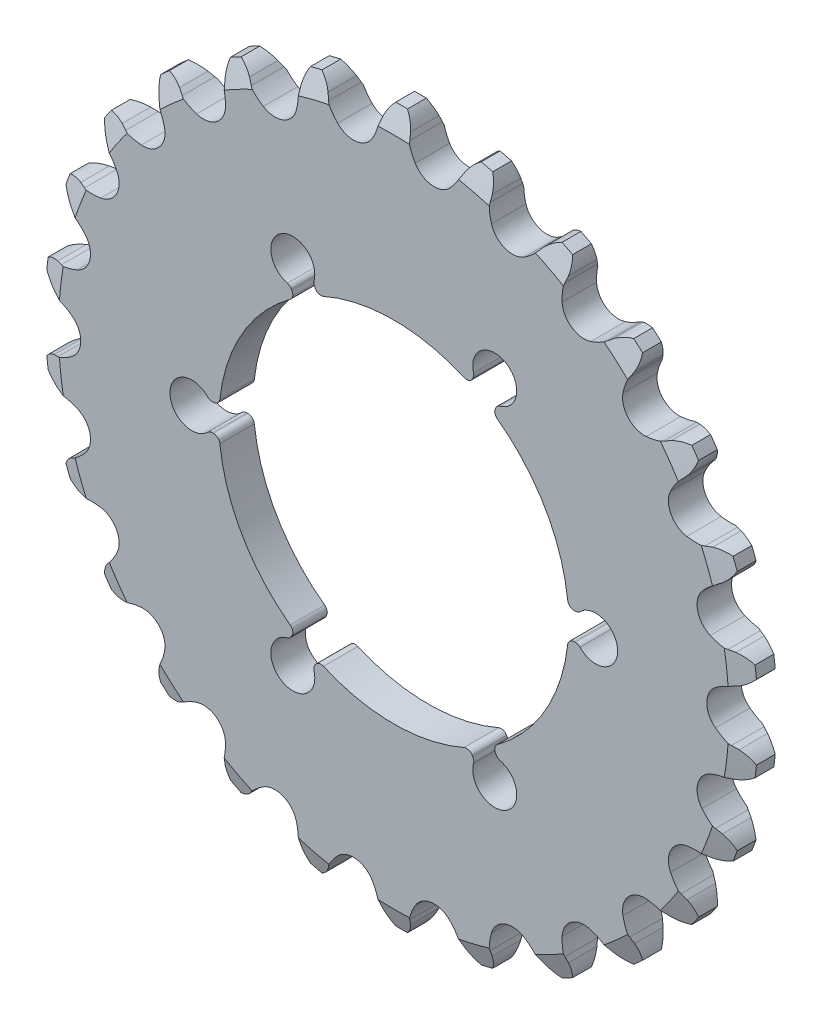
from build123d import *

# Parameters (mm, degrees)
SKETCH1_R         = 42.08018
SKETCH1_R_2       = 20.6375
EXTRUDE1_DEPTH    = 2.032
EXTRUDE2_DEPTH    = 3.032
CIRPATTERN1_COUNT = 6
CHAMFER1_SIZE     = 2.54
CHAMFER1_SIZE2    = 0.924484395
CHAMFER2_SIZE     = 2.54
CHAMFER2_SIZE2    = 0.924484395
EXTRUDE3_DEPTH    = 3.032
CIRPATTERN2_COUNT = 26
FILLET1_R         = 0.762


with BuildPart() as part:
    # Sketch1 → Extrude1 (new body, symmetric)
    with BuildSketch(Plane.XY):
        Circle(SKETCH1_R)
        Circle(SKETCH1_R_2, mode=Mode.SUBTRACT)
    extrude(amount=EXTRUDE1_DEPTH, both=True)

    # Sketch2 → Extrude2 (cut, symmetric)
    with BuildSketch(Plane.XY):
        with BuildLine():
            Line((8.91336053, 18.613393305), (9.507705167, 19.642828413))
            ThreePointArc((9.507705167, 19.642828413), (13.20165, 22.865928544), (12.257335824, 18.055328413))
            Line((12.257335824, 18.055328413), (11.662991187, 17.025893305))
            ThreePointArc((11.662991187, 17.025893305), (10.31875, 17.872599271), (8.91336053, 18.613393305))
        make_face()
    extrude2 = extrude(amount=EXTRUDE2_DEPTH, both=True, mode=Mode.SUBTRACT)

    # CirPattern1: Extrude2 ×6 about axis
    cirpattern1_axis = Axis((0, 0, 0), (0, 0, 1))
    for i in range(1, CIRPATTERN1_COUNT):
        add(extrude2.rotate(cirpattern1_axis, i * 360 / CIRPATTERN1_COUNT), mode=Mode.SUBTRACT)

    # Chamfer1
    chamfer1_edges = [part.edges().sort_by_distance(p)[0] for p in [
        (-42.08018, 0, 2.032),
    ]]
    chamfer1_side = [part.faces().sort_by_distance(p)[0] for p in [
        (-40.889972775, 0, 2.032),
    ]]
    chamfer(chamfer1_edges, length=CHAMFER1_SIZE, length2=CHAMFER1_SIZE2, reference=chamfer1_side[0])

    # Chamfer2
    chamfer2_edges = [part.edges().sort_by_distance(p)[0] for p in [
        (-42.08018, 0, -2.032),
    ]]
    chamfer2_side = [part.faces().sort_by_distance(p)[0] for p in [
        (-40.889972775, 0, -2.032),
    ]]
    chamfer(chamfer2_edges, length=CHAMFER2_SIZE, length2=CHAMFER2_SIZE2, reference=chamfer2_side[0])

    # Sketch3 → Extrude3 (cut, symmetric)
    with BuildSketch(Plane.XY):
        with BuildLine():
            Line((1.783603898, 39.799359762), (1.630155707, 40.477947689))
            ThreePointArc((1.630155707, 40.477947689), (1.253812639, 41.328387), (0.6985, 42.074382308))
            ThreePointArc((0.6985, 42.074382308), (5.072205202, 41.77336811), (9.390855892, 41.018939217))
            ThreePointArc((9.390855892, 41.018939217), (8.673151267, 40.427516189), (8.104220595, 39.691853891))
            Line((8.104220595, 39.691853891), (7.792834609, 39.069707052))
            ThreePointArc((7.792834609, 39.069707052), (7.271379963, 38.200463336), (6.623864243, 37.420576821))
            ThreePointArc((6.623864243, 37.420576821), (4.450208219, 36.650762084), (2.523943414, 37.918397339))
            ThreePointArc((2.523943414, 37.918397339), (2.081882383, 38.830582424), (1.783603898, 39.799359762))
        make_face()
    extrude3 = extrude(amount=EXTRUDE3_DEPTH, both=True, mode=Mode.SUBTRACT)

    # CirPattern2: Extrude3 ×26 about axis
    cirpattern2_axis = Axis((0, 0, 0), (0, 0, 1))
    for i in range(1, CIRPATTERN2_COUNT):
        add(extrude3.rotate(cirpattern2_axis, i * 360 / CIRPATTERN2_COUNT), mode=Mode.SUBTRACT)

    # Fillet1
    fillet1_edges = [part.edges().sort_by_distance(p)[0] for p in [
        (9.507705167, 19.642828413, 0),
        (12.257335824, 18.055328413, 0),
        (11.662991187, 17.025893305, 0),
        (8.91336053, 18.613393305, 0),
        (21.765040992, 1.5875, 0),
        (21.765040992, -1.5875, 0),
        (20.576351717, -1.5875, 0),
        (20.576351717, 1.5875, 0),
        (12.257335824, -18.055328413, 0),
        (9.507705167, -19.642828413, 0),
        (8.91336053, -18.613393305, 0),
        (11.662991187, -17.025893305, 0),
        (-9.507705167, -19.642828413, 0),
        (-12.257335824, -18.055328413, 0),
        (-11.662991187, -17.025893305, 0),
        (-8.91336053, -18.613393305, 0),
        (-21.765040992, -1.5875, 0),
        (-21.765040992, 1.5875, 0),
        (-20.576351717, 1.5875, 0),
        (-20.576351717, -1.5875, 0),
        (-12.257335824, 18.055328413, 0),
        (-9.507705167, 19.642828413, 0),
        (-8.91336053, 18.613393305, 0),
        (-11.662991187, 17.025893305, 0),
    ]]
    fillet(fillet1_edges, radius=FILLET1_R)


solid = part.part
